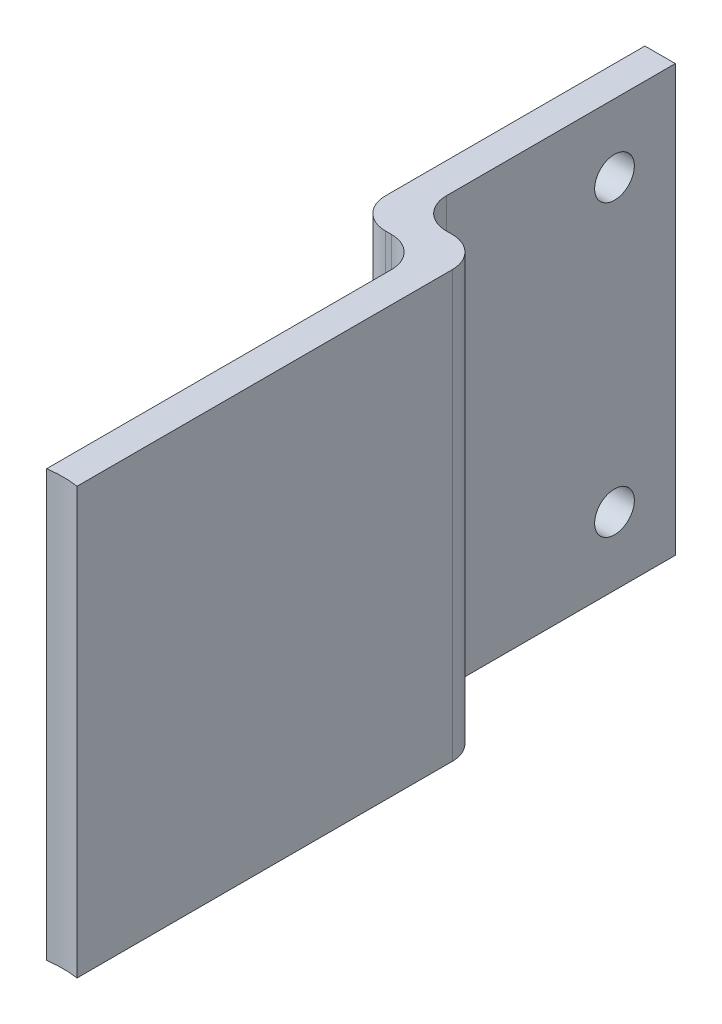
from build123d import *

# Parameters (mm, degrees)
BOSS_EXTRUDE1_DEPTH = 70
SKETCH2_R           = 3.2639
CUT_EXTRUDE1_DEPTH  = 70
SKETCH3_R           = 17.5
CUT_EXTRUDE2_DEPTH  = 71


with BuildPart() as part:
    # Sketch1 → Boss-Extrude1 (new body)
    with BuildSketch(Plane(origin=(0, 0, 0), x_dir=(1, 0, 0), z_dir=(0, 1, 0))):
        with BuildLine():
            Line((0, -5), (0, -85))
            Line((0, -85), (5, -85))
            Line((5, -85), (5, 0))
            ThreePointArc((5, 0), (3.535533906, 3.535533906), (0, 5))
            Line((0, 5), (-1, 5))
            ThreePointArc((-1, 5), (-4.535533906, 6.464466094), (-6, 10))
            Line((-6, 10), (-6, 47.65))
            Line((-6, 47.65), (-11, 47.65))
            Line((-11, 47.65), (-11, 5))
            ThreePointArc((-11, 5), (-9.535533906, 1.464466094), (-6, 0))
            Line((-6, 0), (-5, 0))
            ThreePointArc((-5, 0), (-1.464466094, -1.464466094), (0, -5))
        make_face()
    extrude(amount=BOSS_EXTRUDE1_DEPTH)

    # Sketch2 → Cut-Extrude1 (cut)
    with BuildSketch(Plane(origin=(-6, 0, 0), x_dir=(0, 0, -1), z_dir=(1, 0, 0))):
        with Locations((37.65, 58.8125)):
            Circle(SKETCH2_R)
        with Locations((37.65, 11.1875)):
            Circle(SKETCH2_R)
    extrude(amount=-CUT_EXTRUDE1_DEPTH, mode=Mode.SUBTRACT)

    # Sketch3 → Cut-Extrude2 (cut, through all)
    with BuildSketch(Plane(origin=(0, 70, 0), x_dir=(1, 0, 0), z_dir=(0, 1, 0))):
        with Locations((2.5, -79)):
            Circle(SKETCH3_R)
    extrude(amount=-CUT_EXTRUDE2_DEPTH, mode=Mode.SUBTRACT)


solid = part.part
